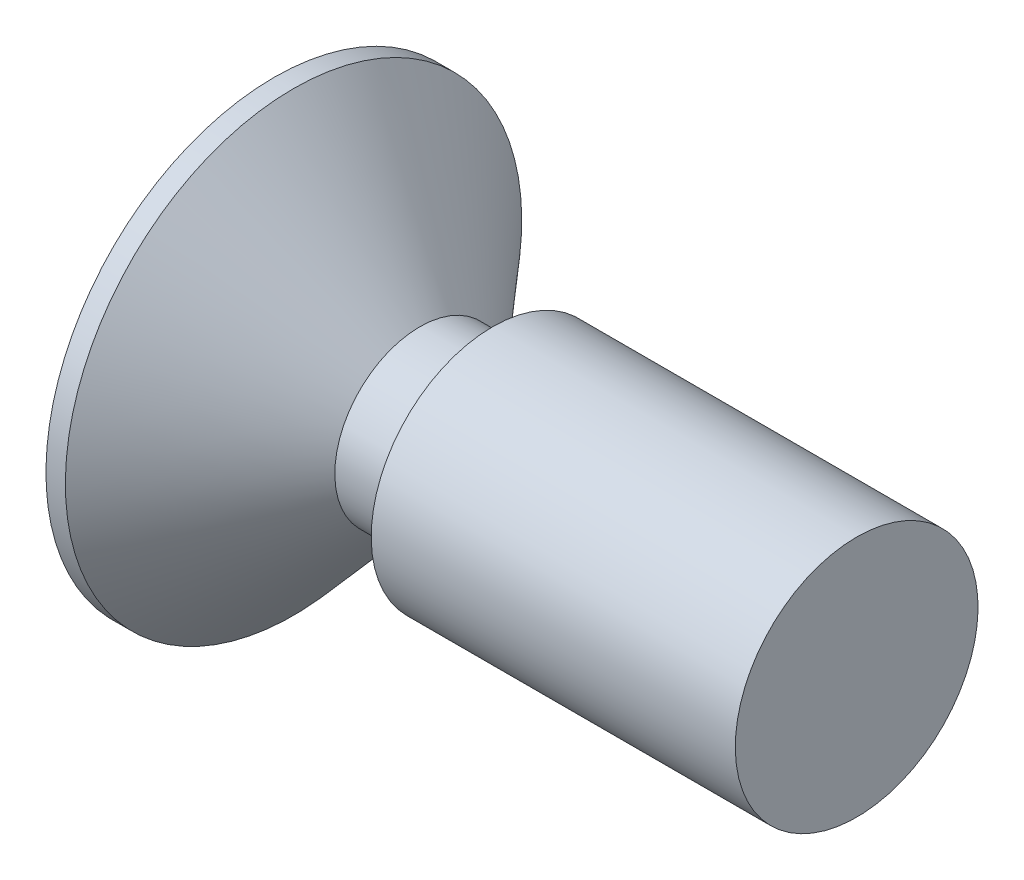
from build123d import *

# Parameters (mm, degrees)
CUT_EXTRUDE_1_DEPTH = 0.75


with BuildPart() as part:
    # 草图1 → 旋转1 (revolve)
    with BuildSketch(Plane.XY):
        Polygon((0, 0), (0, 1.25), (-3.75, 1.25), (-3.75, 0.875), (-4.5, 0.875), (-5.8, 2.35), (-6, 2.35), (-6, 0), align=None)
    revolve(axis=Axis((0, 0, 0), (-1, 0, 0)))

    # 草图2 → 切除-拉伸1 (cut)
    with BuildSketch(Plane.ZY.offset(6)):
        with BuildLine():
            Line((-0.3125, 1.5), (0.3125, 1.5))
            Line((0.3125, 1.5), (0.3125, 0.5625))
            ThreePointArc((0.3125, 0.5625), (0.385723305, 0.385723305), (0.5625, 0.3125))
            Line((0.5625, 0.3125), (1.5, 0.3125))
            Line((1.5, 0.3125), (1.5, -0.3125))
            Line((1.5, -0.3125), (0.5625, -0.3125))
            ThreePointArc((0.5625, -0.3125), (0.385723305, -0.385723305), (0.3125, -0.5625))
            Line((0.3125, -0.5625), (0.3125, -1.5))
            Line((0.3125, -1.5), (-0.3125, -1.5))
            Line((-0.3125, -1.5), (-0.3125, -0.5625))
            ThreePointArc((-0.3125, -0.5625), (-0.385723305, -0.385723305), (-0.5625, -0.3125))
            Line((-0.5625, -0.3125), (-1.5, -0.3125))
            Line((-1.5, -0.3125), (-1.5, 0.3125))
            Line((-1.5, 0.3125), (-0.5625, 0.3125))
            ThreePointArc((-0.5625, 0.3125), (-0.385723305, 0.385723305), (-0.3125, 0.5625))
            Line((-0.3125, 0.5625), (-0.3125, 1.5))
        make_face()
    extrude(amount=-CUT_EXTRUDE_1_DEPTH, mode=Mode.SUBTRACT)


solid = part.part
